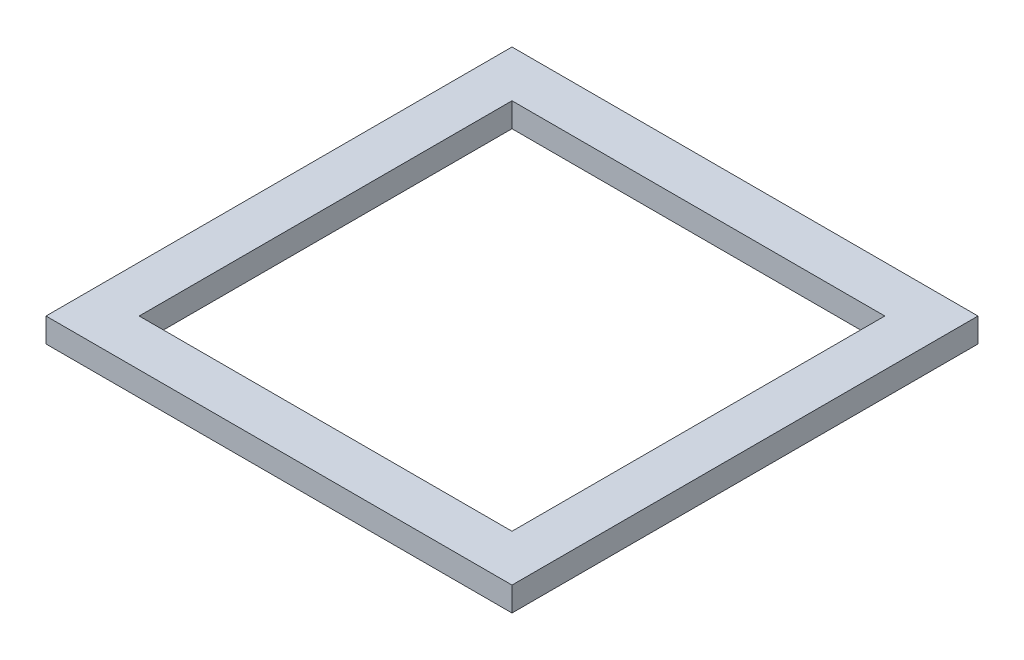
from build123d import *

# Parameters (mm, degrees)
SKETCH1_W           = 88.9
SKETCH1_H           = 88.9
SKETCH1_R           = 2.032
SKETCH1_W_2         = 63.5
SKETCH1_H_2         = 63.5
SKETCH1_W_3         = 50.8
SKETCH1_H_3         = 50.8
BOSS_EXTRUDE2_DEPTH = 3.175
BOSS_EXTRUDE3_START = 3.175
SKETCH1_4_W         = 63.5
SKETCH1_4_H         = 63.5
SKETCH1_4_W_2       = 50.8
SKETCH1_4_H_2       = 50.8
BOSS_EXTRUDE3_DEPTH = 3.302
SKETCH2_W           = 88.9
SKETCH2_H           = 88.9
CUT_EXTRUDE1_DEPTH  = 4.175


with BuildPart() as part:
    # Sketch1 → Boss-Extrude2 (new body)
    with BuildSketch(Plane(origin=(0, 0, 0), x_dir=(1, 0, 0), z_dir=(0, 1, 0))):
        Rectangle(SKETCH1_W, SKETCH1_H)
        with Locations((38.1, 38.1)):
            Circle(SKETCH1_R, mode=Mode.SUBTRACT)
        with Locations((-38.1, 38.1)):
            Circle(SKETCH1_R, mode=Mode.SUBTRACT)
        with Locations((38.1, -38.1)):
            Circle(SKETCH1_R, mode=Mode.SUBTRACT)
        with Locations((-38.1, -38.1)):
            Circle(SKETCH1_R, mode=Mode.SUBTRACT)
        Rectangle(SKETCH1_W_2, SKETCH1_H_2, mode=Mode.SUBTRACT)
        Rectangle(SKETCH1_W_3, SKETCH1_H_3)
        Rectangle(SKETCH1_W_2, SKETCH1_H_2)
        Rectangle(SKETCH1_W_3, SKETCH1_H_3, mode=Mode.SUBTRACT)
    extrude(amount=BOSS_EXTRUDE2_DEPTH)

    # Sketch1_4 → Boss-Extrude3 (add)
    with BuildSketch(Plane(origin=(0, 0, 0), x_dir=(1, 0, 0), z_dir=(0, 1, 0)).offset(BOSS_EXTRUDE3_START)):
        Rectangle(SKETCH1_4_W, SKETCH1_4_H)
        Rectangle(SKETCH1_4_W_2, SKETCH1_4_H_2, mode=Mode.SUBTRACT)
    extrude(amount=BOSS_EXTRUDE3_DEPTH)

    # Sketch2 → Cut-Extrude1 (cut, through all)
    with BuildSketch(Plane(origin=(0, 3.175, 0), x_dir=(1, 0, 0), z_dir=(0, 1, 0))):
        Rectangle(SKETCH2_W, SKETCH2_H)
    extrude(amount=-CUT_EXTRUDE1_DEPTH, mode=Mode.SUBTRACT)


solid = part.part
